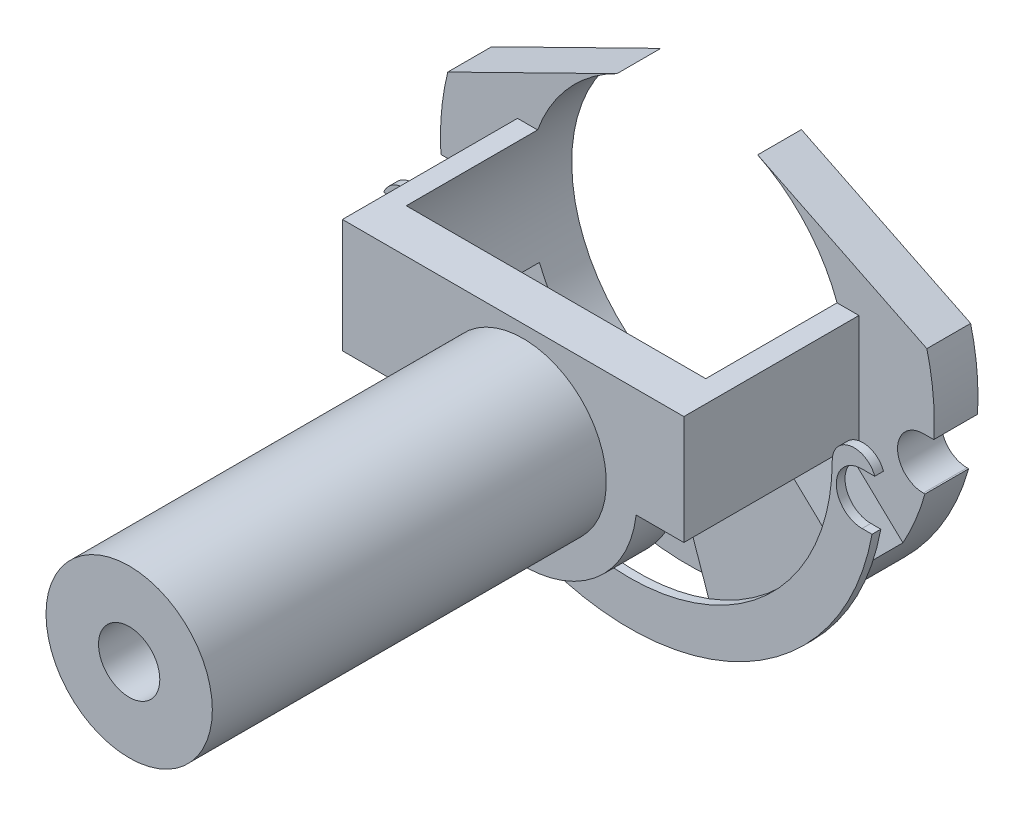
from build123d import *

# Parameters (mm, degrees)
CROQUIS1_R              = 9.5
SALIENTE_EXTRUIR1_DEPTH = 45
SALIENTE_EXTRUIR2_DEPTH = 5
CROQUIS3_W              = 2.5
CROQUIS3_H              = 12.459614936
CROQUIS3_H_2            = 13
SALIENTE_EXTRUIR3_DEPTH = 20
SALIENTE_EXTRUIR4_DEPTH = 5
CORTAR_EXTRUIR1_DEPTH   = 15
CORTAR_EXTRUIR2_DEPTH   = 15
SALIENTE_EXTRUIR6_DEPTH = 6
SALIENTE_EXTRUIR9_DEPTH = 1
CORTAR_EXTRUIR3_DEPTH   = 30
CORTAR_EXTRUIR4_DEPTH   = 30
CROQUIS14_R             = 3.5
CORTAR_EXTRUIR5_DEPTH   = 71


with BuildPart() as part:
    # Croquis1 → Saliente-Extruir1 (new body)
    with BuildSketch(Plane.XY):
        Circle(CROQUIS1_R)
    extrude(amount=SALIENTE_EXTRUIR1_DEPTH)

    # Croquis2 → Saliente-Extruir2 (add)
    with BuildSketch(Plane(origin=(0, 0, 0), x_dir=(-1, 0, 0), z_dir=(0, 0, -1))):
        with BuildLine():
            Line((-13.86026331, 10.949878275), (16.13973669, 10.949878275))
            Line((16.13973669, 10.949878275), (18.13973669, 10.949878275))
            Line((18.13973669, 10.949878275), (18.13973669, -2.050121725))
            Line((18.13973669, -2.050121725), (12.837328418, -2.050121725))
            ThreePointArc((12.837328418, -2.050121725), (-0.272762426, -12.997138172), (-12.912036834, -1.509736661))
            Line((-12.912036834, -1.509736661), (-15.86026331, -1.509736661))
            Line((-15.86026331, -1.509736661), (-15.86026331, 10.949878275))
            Line((-15.86026331, 10.949878275), (-13.86026331, 10.949878275))
        make_face()
    extrude(amount=SALIENTE_EXTRUIR2_DEPTH)

    # Croquis3 → Saliente-Extruir3 (add)
    with BuildSketch(Plane.XY):
        with Locations((17.11026331, 4.720070807)):
            Rectangle(CROQUIS3_W, CROQUIS3_H)
        with Locations((-19.38973669, 4.449878275)):
            Rectangle(CROQUIS3_W, CROQUIS3_H_2)
    extrude(amount=-SALIENTE_EXTRUIR3_DEPTH)

    # Croquis4 → Saliente-Extruir4 (add)
    with BuildSketch(Plane(origin=(0, 0, -20), x_dir=(-1, 0, 0), z_dir=(0, 0, -1))):
        with BuildLine():
            Line((-26.12024366, 11.549093047), (-6.789040969, 21.054674019))
            ThreePointArc((-6.789040969, 21.054674019), (1.243045599, -13.482502548), (9.275132167, 21.054674019))
            Line((9.275132167, 21.054674019), (28.606334858, 11.549093047))
            ThreePointArc((28.606334858, 11.549093047), (1.243045599, -23.482502548), (-26.12024366, 11.549093047))
        make_face()
    extrude(amount=SALIENTE_EXTRUIR4_DEPTH)

    # Croquis5 → Cortar-Extruir1 (cut)
    with BuildSketch(Plane(origin=(0, 0, -20), x_dir=(-1, 0, 0), z_dir=(0, 0, -1))):
        with BuildLine():
            Line((-15.86026331, 10.949878275), (-15.86026331, -1.509736661))
            ThreePointArc((-15.86026331, -1.509736661), (-16.959527756, 4.720070807), (-15.86026331, 10.949878275))
        make_face()
    extrude(amount=-CORTAR_EXTRUIR1_DEPTH, mode=Mode.SUBTRACT)

    # Croquis6 → Cortar-Extruir2 (cut)
    with BuildSketch(Plane(origin=(0, 0, -20), x_dir=(-1, 0, 0), z_dir=(0, 0, -1))):
        with BuildLine():
            Line((18.13973669, -2.050121725), (18.13973669, 10.949878275))
            Line((18.13973669, 10.949878275), (18.346354508, 10.949878275))
            ThreePointArc((18.346354508, 10.949878275), (19.443320322, 4.430801495), (18.13973669, -2.050121725))
        make_face()
    extrude(amount=-CORTAR_EXTRUIR2_DEPTH, mode=Mode.SUBTRACT)

    # Croquis8 → Saliente-Extruir6 (add)
    with BuildSketch(Plane.XY.offset(-20)):
        with BuildLine():
            Line((23.380531683, -9.030005034), (15.754093987, -1.793831452))
            ThreePointArc((15.754093987, -1.793831452), (11.418506022, -8.357344354), (4.718355695, -12.478631799))
            Line((4.718355695, -12.478631799), (7.993387845, -21.927132443))
            ThreePointArc((7.993387845, -21.927132443), (16.873495336, -16.894185793), (23.380531683, -9.030005034))
        make_face()
    extrude(amount=SALIENTE_EXTRUIR6_DEPTH)

    # Croquis10 → Saliente-Extruir9 (add)
    with BuildSketch(Plane.XY.offset(-14)):
        with BuildLine():
            ThreePointArc((-29.094443415, 2.096360018), (-0.89187006, -26.106213336), (27.310703295, 2.096360018))
            ThreePointArc((27.310703295, 2.096360018), (24.810703295, 4.596360018), (22.310703295, 2.096360018))
            ThreePointArc((22.310703295, 2.096360018), (-0.89187006, -21.106213336), (-24.094443415, 2.096360018))
            ThreePointArc((-24.094443415, 2.096360018), (-26.594443415, 4.596360018), (-29.094443415, 2.096360018))
        make_face()
    extrude(amount=SALIENTE_EXTRUIR9_DEPTH)

    # Croquis12 → Cortar-Extruir3 (cut)
    with BuildSketch(Plane.XY.offset(-13)):
        with BuildLine():
            Line((-27.563915972, 3), (-28.925416341, 3))
            Line((-28.925416341, 3), (-33.584272261, 3))
            Line((-33.584272261, 3), (-33.584272261, -3))
            Line((-33.584272261, -3), (-28.63015152, -3))
            Line((-28.63015152, -3), (-27.563915972, -3))
            ThreePointArc((-27.563915972, -3), (-24.563915972, 0), (-27.563915972, 3))
        make_face()
    extrude(amount=-CORTAR_EXTRUIR3_DEPTH, mode=Mode.SUBTRACT)

    # Croquis13 → Cortar-Extruir4 (cut)
    with BuildSketch(Plane.XY.offset(-13)):
        with BuildLine():
            Line((25.714967949, 2.943204688), (33.854636773, 2.943204688))
            Line((33.854636773, 2.943204688), (33.854636773, -2.943204688))
            Line((33.854636773, -2.943204688), (25.714967949, -2.943204688))
            ThreePointArc((25.714967949, -2.943204688), (22.771763261, 0), (25.714967949, 2.943204688))
        make_face()
    extrude(amount=-CORTAR_EXTRUIR4_DEPTH, mode=Mode.SUBTRACT)

    # Croquis14 → Cortar-Extruir5 (cut, through all)
    with BuildSketch(Plane.XY.offset(45)):
        Circle(CROQUIS14_R)
    extrude(amount=-CORTAR_EXTRUIR5_DEPTH, mode=Mode.SUBTRACT)


solid = part.part
